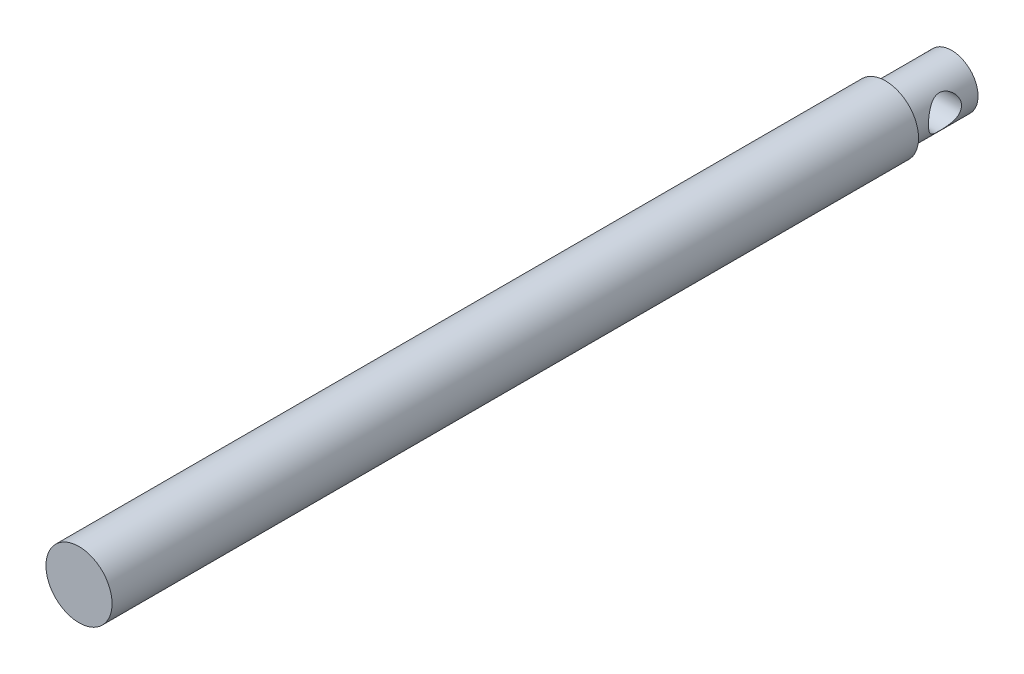
from build123d import *

# Parameters (mm, degrees)
SKETCH1_R               = 5
BOSS_EXTRUDE1_DEPTH     = 122
SKETCH2_R               = 4
BOSS_EXTRUDE2_DEPTH     = 10
SKETCH3_R               = 2.5
CUT_EXTRUDE1_DEPTH      = 6
CUT_EXTRUDE1_DEPTH_BACK = 6


with BuildPart() as part:
    # Sketch1 → Boss-Extrude1 (new body)
    with BuildSketch(Plane.XY):
        Circle(SKETCH1_R)
    extrude(amount=BOSS_EXTRUDE1_DEPTH)

    # Sketch2 → Boss-Extrude2 (add)
    with BuildSketch(Plane(origin=(0, 0, 0), x_dir=(-1, 0, 0), z_dir=(0, 0, -1))):
        Circle(SKETCH2_R)
    extrude(amount=BOSS_EXTRUDE2_DEPTH)

    # Sketch3 → Cut-Extrude1 (cut, two sides)
    with BuildSketch(Plane(origin=(0, 0, 0), x_dir=(0, 0, -1), z_dir=(1, 0, 0))) as cut_extrude1_sk:
        with Locations((5, 0)):
            Circle(SKETCH3_R)
    extrude(amount=CUT_EXTRUDE1_DEPTH, mode=Mode.SUBTRACT)
    extrude(cut_extrude1_sk.sketch, amount=-CUT_EXTRUDE1_DEPTH_BACK, mode=Mode.SUBTRACT)


solid = part.part
